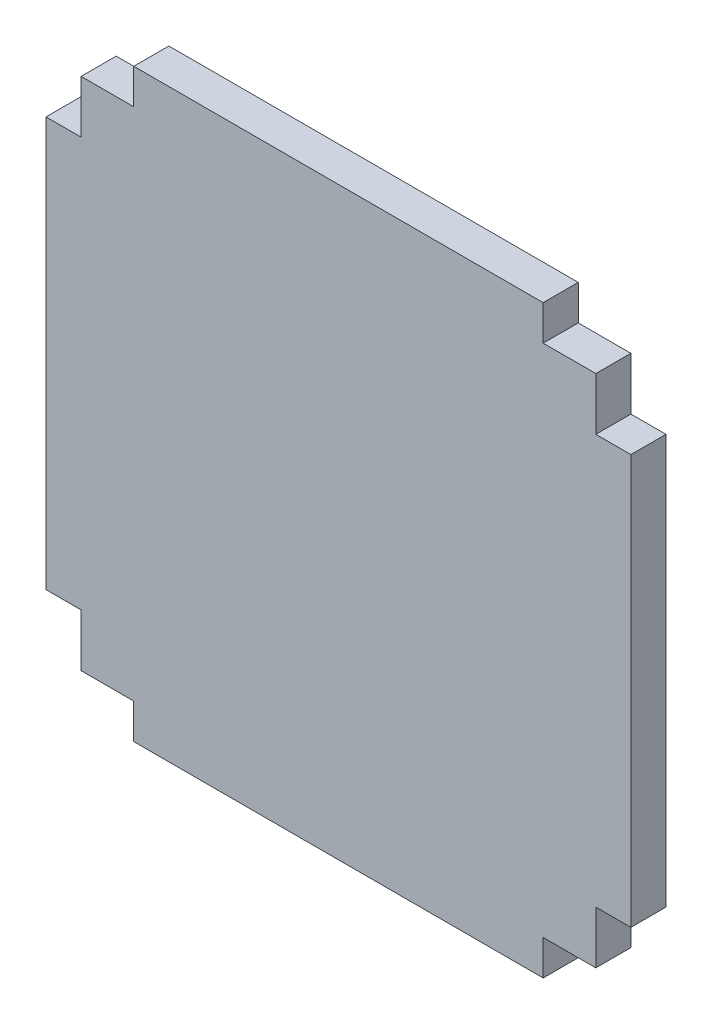
from build123d import *

# Parameters (mm, degrees)
SCHIZZO1_W                   = 35
SCHIZZO1_H                   = 3
SCHIZZO1_W_2                 = 3
SCHIZZO1_H_2                 = 35
ESTRUSIONE_ESTRUSIONE2_DEPTH = 3


with BuildPart() as part:
    # Schizzo1 → Estrusione-Estrusione2 (new body)
    with BuildSketch(Plane.XY):
        Polygon((-22, -17.5), (-22, -22), (-17.5, -22), (17.5, -22), (22, -22), (22, -17.5), (22, 17.5), (22, 22), (17.5, 22), (-17.5, 22), (-22, 22), (-22, 17.5), align=None)
        with Locations((0, -23.5)):
            Rectangle(SCHIZZO1_W, SCHIZZO1_H)
        with Locations((23.5, 0)):
            Rectangle(SCHIZZO1_W_2, SCHIZZO1_H_2)
        with Locations((-23.5, 0)):
            Rectangle(SCHIZZO1_W_2, SCHIZZO1_H_2)
        with Locations((0, 23.5)):
            Rectangle(SCHIZZO1_W, SCHIZZO1_H)
    extrude(amount=ESTRUSIONE_ESTRUSIONE2_DEPTH)


solid = part.part
